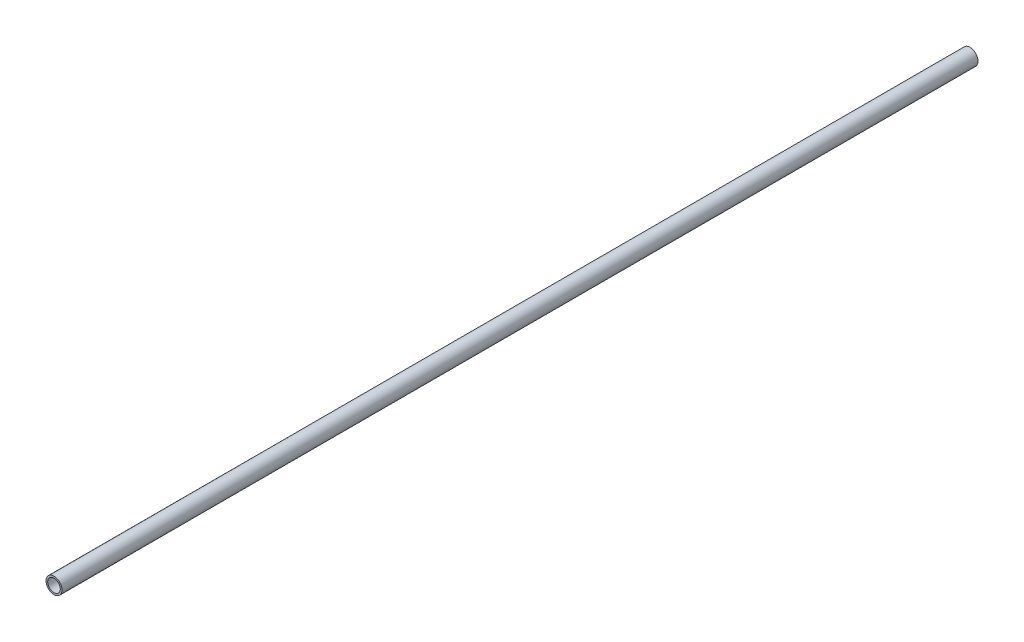
from build123d import *

# Parameters (mm, degrees)
SKETCH3_R                = 13.335
SKETCH3_R_2              = 10.4648
BOSS_EXTRUDE1_DEPTH      = 762
BOSS_EXTRUDE1_DEPTH_BACK = 762


with BuildPart() as part:
    # Sketch3 → Boss-Extrude1 (new body, two sides)
    with BuildSketch(Plane.XY) as boss_extrude1_sk:
        Circle(SKETCH3_R)
        Circle(SKETCH3_R_2, mode=Mode.SUBTRACT)
    extrude(amount=BOSS_EXTRUDE1_DEPTH)
    extrude(boss_extrude1_sk.sketch, amount=-BOSS_EXTRUDE1_DEPTH_BACK)


solid = part.part
